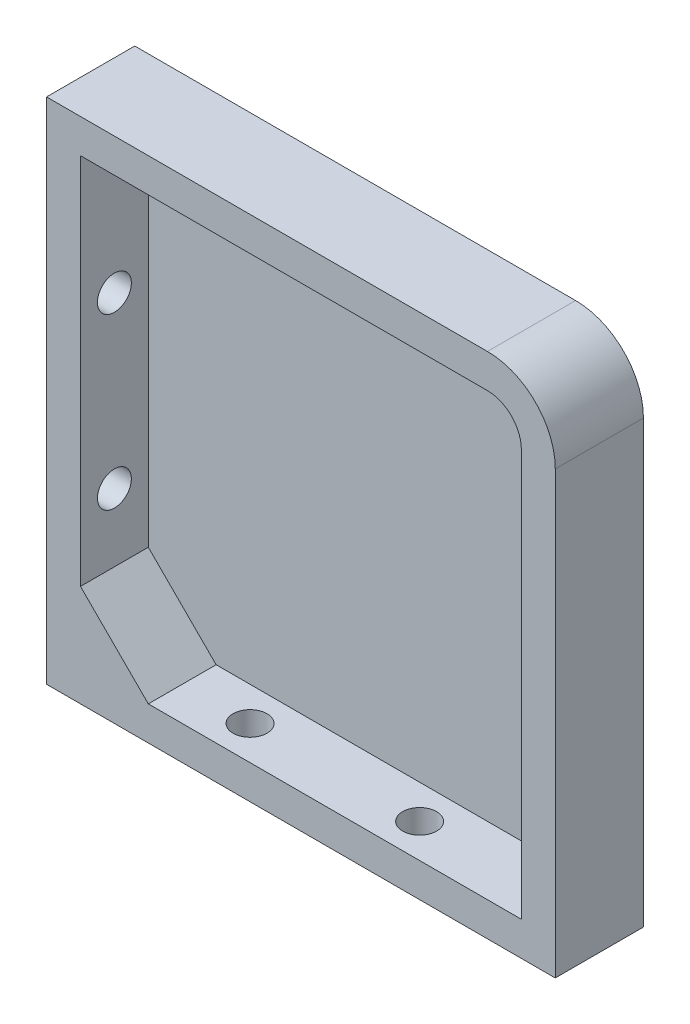
from build123d import *

# Parameters (mm, degrees)
BOSS_EXTRU_1_DEPTH       = 13
COQUE1_T                 = -5
COQUE1_THICKNESS_2_DEPTH = 2
ESQUISSE2_R              = 2.5
ENL_V_MAT_EXTRU_1_DEPTH  = 5
ESQUISSE3_R              = 2.5
ENL_V_MAT_EXTRU_2_DEPTH  = 5
BOSS_EXTRU_2_DEPTH       = 10


with BuildPart() as part:
    # Esquisse1 → Boss.-Extru.1 (new body)
    with BuildSketch(Plane.XY):
        with BuildLine():
            Line((-20.881563692, 33.728448276), (44.118436308, 33.728448276))
            ThreePointArc((44.118436308, 33.728448276), (51.18950412, 30.799516088), (54.118436308, 23.728448276))
            Line((54.118436308, 23.728448276), (54.118436308, -41.271551724))
            Line((54.118436308, -41.271551724), (-20.881563692, -41.271551724))
            Line((-20.881563692, -41.271551724), (-20.881563692, 33.728448276))
        make_face()
    extrude(amount=BOSS_EXTRU_1_DEPTH)

    # Coque1
    coque1_openings = [part.faces().sort_by_distance(p)[0] for p in [
        (16.483374946, -3.906613086, 13),
    ]]
    offset(amount=COQUE1_T, openings=coque1_openings, kind=Kind.INTERSECTION)

    # Coque1 thickness 2 face (on inner face of the shell) → Coque1 thickness 2 (cut)
    with BuildSketch(Plane(origin=(16.578534255, -3.811453777, 5), x_dir=(-1, 0, 0), z_dir=(0, 0, -1))):
        with BuildLine():
            Line((-27.539902053, 32.539902053), (32.460097947, 32.539902053))
            Line((32.460097947, 32.539902053), (32.460097947, -32.460097947))
            Line((32.460097947, -32.460097947), (-32.539902053, -32.460097947))
            Line((-32.539902053, -32.460097947), (-32.539902053, 27.539902053))
            ThreePointArc((-32.539902053, 27.539902053), (-31.075435959, 31.075435959), (-27.539902053, 32.539902053))
        make_face()
    extrude(amount=COQUE1_THICKNESS_2_DEPTH, mode=Mode.SUBTRACT)

    # Esquisse2 → Enlèv. mat.-Extru.1 (cut)
    with BuildSketch(Plane.ZY.offset(20.881563692)):
        with Locations(Location((8, -16.271551724, 0), (0, 0, 270))):
            Circle(ESQUISSE2_R)
        with Locations(Location((8, 8.728448276, 0), (0, 0, 270))):
            Circle(ESQUISSE2_R)
    extrude(amount=-ENL_V_MAT_EXTRU_1_DEPTH, mode=Mode.SUBTRACT)

    # Esquisse3 → Enlèv. mat.-Extru.2 (cut)
    with BuildSketch(Plane.XZ.offset(41.271551724)):
        with Locations(Location((4.118436308, 8, 0), (0, 0, 270))):
            Circle(ESQUISSE3_R)
        with Locations(Location((29.118436308, 8, 0), (0, 0, 270))):
            Circle(ESQUISSE3_R)
    extrude(amount=-ENL_V_MAT_EXTRU_2_DEPTH, mode=Mode.SUBTRACT)

    # Esquisse4 → Boss.-Extru.2 (add)
    with BuildSketch(Plane.XY.offset(3)):
        Polygon((-15.881563692, -26.271551724), (-5.881563692, -36.271551724), (-15.881563692, -36.271551724), align=None)
    extrude(amount=BOSS_EXTRU_2_DEPTH)


solid = part.part
